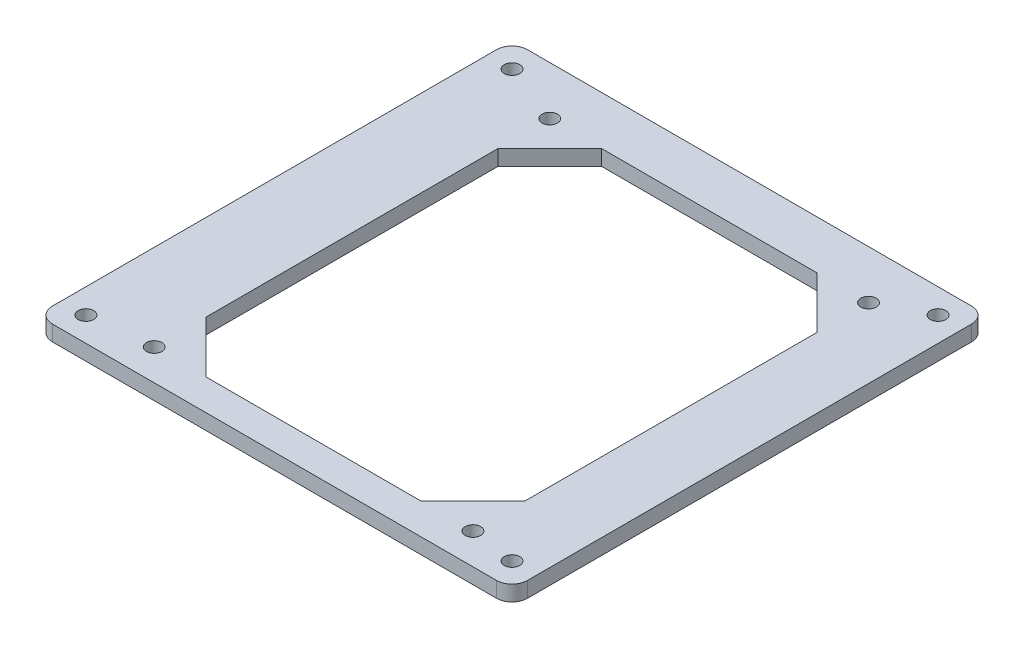
from build123d import *

# Parameters (mm, degrees)
SKETCH_1_R      = 1.5
EXTRUDE_1_DEPTH = 3


with BuildPart() as part:
    # 草圖1 → 填料-伸長1 (new body)
    with BuildSketch(Plane(origin=(0, 3, 0), x_dir=(1, 0, 0), z_dir=(0, 1, 0))):
        with BuildLine():
            Line((-46, 43), (-46, -43))
            ThreePointArc((-46, -43), (-45.121320344, -45.121320344), (-43, -46))
            Line((-43, -46), (43, -46))
            ThreePointArc((43, -46), (45.121320344, -45.121320344), (46, -43))
            Line((46, -43), (46, 43))
            ThreePointArc((46, 43), (45.121320344, 45.121320344), (43, 46))
            Line((43, 46), (-43, 46))
            ThreePointArc((-43, 46), (-45.121320344, 45.121320344), (-46, 43))
        make_face()
        with Locations((-29.285, 36.6)):
            Circle(SKETCH_1_R, mode=Mode.SUBTRACT)
        with Locations((32.435, 36.6)):
            Circle(SKETCH_1_R, mode=Mode.SUBTRACT)
        with Locations((32.435, -40)):
            Circle(SKETCH_1_R, mode=Mode.SUBTRACT)
        with Locations((-29.285, -40)):
            Circle(SKETCH_1_R, mode=Mode.SUBTRACT)
        with Locations((41.25, -41.25)):
            Circle(SKETCH_1_R, mode=Mode.SUBTRACT)
        with Locations((-41.25, 41.25)):
            Circle(SKETCH_1_R, mode=Mode.SUBTRACT)
        with Locations((41.25, 41.25)):
            Circle(SKETCH_1_R, mode=Mode.SUBTRACT)
        with Locations((-41.25, -41.25)):
            Circle(SKETCH_1_R, mode=Mode.SUBTRACT)
        Polygon((-19.285, 36.6), (22.435, 36.6), (32.435, 26.6), (32.435, -30), (22.435, -40), (-19.285, -40), (-29.285, -30), (-29.285, 26.6), align=None, mode=Mode.SUBTRACT)
    extrude(amount=-EXTRUDE_1_DEPTH)


solid = part.part
